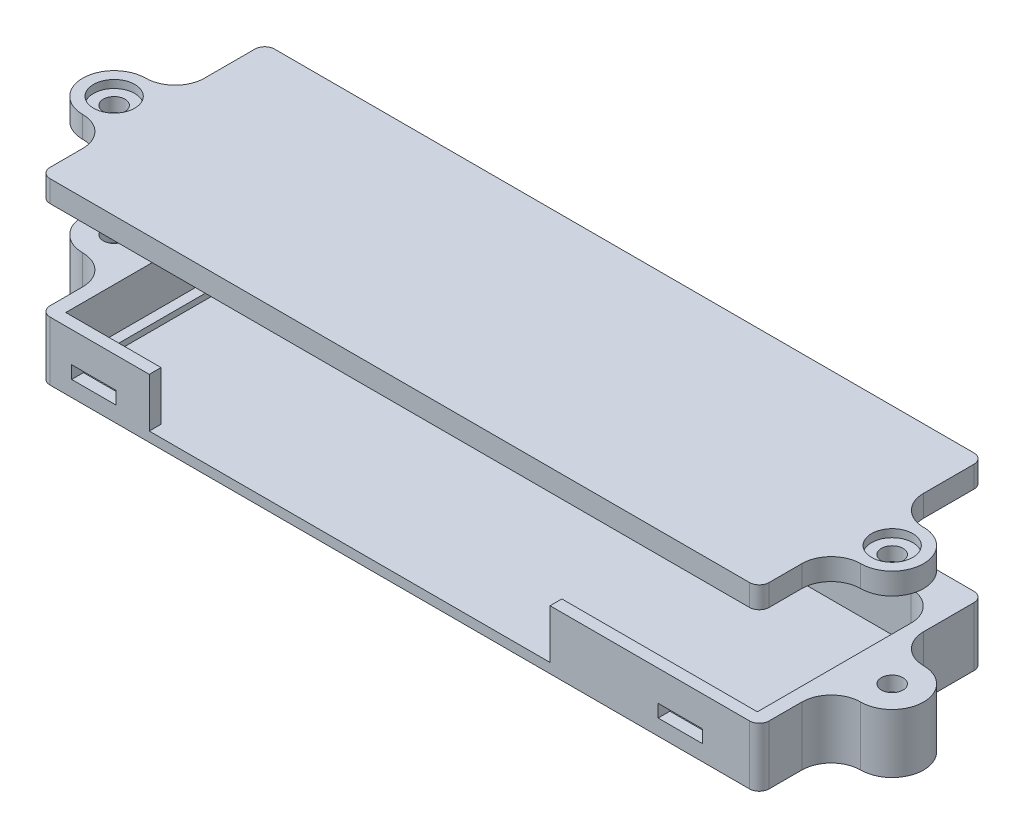
from build123d import *

# Parameters (mm, degrees)
SKETCH_1_W          = 73.2
SKETCH_1_H          = 22.85
EXTRUDE_1_DEPTH     = 5
SKETCH_2_W          = 73.2
SKETCH_2_H          = 22.85
EXTRUDE_2_DEPTH     = 1
SKETCH_3_W          = 1
SKETCH_3_H          = 14.570353531
EXTRUDE_3_DEPTH     = 0.6
CUT_EXTRUDE_1_REACH = 24.85
SKETCH_4_W          = 10.95
SKETCH_4_H          = 5
CUT_EXTRUDE_2_REACH = 24.85
SKETCH_5_W          = 40.8
SKETCH_5_H          = 5
SKETCH_5_W_2        = 4.5
SKETCH_5_H_2        = 1.3
FILLET_1_R          = 1
SKETCH_6_R          = 1.1
EXTRUDE_4_DEPTH     = 6
CUT_EXTRUDE_3_DEPTH = 4.5
SKETCH_8_R          = 1.1
EXTRUDE_5_DEPTH     = 2.2
SKETCH_9_R          = 2.1
CUT_EXTRUDE_4_DEPTH = 0.8


with BuildPart() as part:
    # 草图1 → 凸台-拉伸1 (new body)
    with BuildSketch(Plane(origin=(0, 0, 0), x_dir=(1, 0, 0), z_dir=(0, 1, 0))):
        with Locations((0, 0.9)):
            Rectangle(SKETCH_1_W, SKETCH_1_H)
        with BuildLine():
            Line((-35.2, -9.325), (35.2, -9.325))
            Line((35.2, -9.325), (35.2, 6.325))
            ThreePointArc((35.2, 6.325), (34.321320344, 8.446320344), (32.2, 9.325))
            Line((32.2, 9.325), (-35.2, 9.325))
            Line((-35.2, 9.325), (-35.2, -9.325))
        make_face(mode=Mode.SUBTRACT)
    extrude(amount=EXTRUDE_1_DEPTH)

    # 草图2 → 凸台-拉伸2 (add)
    with BuildSketch(Plane.XZ):
        with Locations((0, -0.9)):
            Rectangle(SKETCH_2_W, SKETCH_2_H)
    extrude(amount=EXTRUDE_2_DEPTH)

    # 草图3 → 凸台-拉伸3 (add)
    with BuildSketch(Plane(origin=(0, 0, 0), x_dir=(1, 0, 0), z_dir=(0, 1, 0))):
        with Locations((-34.7, -0.005928717)):
            Rectangle(SKETCH_3_W, SKETCH_3_H)
        with Locations((34.7, -0.005928717)):
            Rectangle(SKETCH_3_W, SKETCH_3_H)
    extrude(amount=EXTRUDE_3_DEPTH)

    # 草图4 → 切除-拉伸1 (cut, up to next)
    with BuildSketch(Plane(origin=(0, 0, -12.325), x_dir=(-1, 0, 0), z_dir=(0, 0, -1)), mode=Mode.PRIVATE) as cut_extrude_1_sk1:
        with Locations((23.425, 2.5)):
            Rectangle(SKETCH_4_W, SKETCH_4_H)
    cut_extrude_1_tool1 = extrude(cut_extrude_1_sk1.sketch, amount=-CUT_EXTRUDE_1_REACH, mode=Mode.PRIVATE) & part.part
    add(cut_extrude_1_tool1.solids().sort_by_distance((-23.425, 2.5, -12.325))[0], mode=Mode.SUBTRACT)

    # 草图5 → 切除-拉伸2 (cut, up to next)
    with BuildSketch(Plane.XY.offset(10.525), mode=Mode.PRIVATE) as cut_extrude_2_sk1:
        with Locations((-5.1, 2.5)):
            Rectangle(SKETCH_5_W, SKETCH_5_H)
    cut_extrude_2_tool1 = extrude(cut_extrude_2_sk1.sketch, amount=-CUT_EXTRUDE_2_REACH, mode=Mode.PRIVATE) & part.part
    add(cut_extrude_2_tool1.solids().sort_by_distance((-5.1, 2.5, 10.525))[0], mode=Mode.SUBTRACT)
    # 草图5 → 切除-拉伸2 (cut, up to next)
    with BuildSketch(Plane.XY.offset(10.525), mode=Mode.PRIVATE) as cut_extrude_2_sk2:
        with Locations((-31.15, 1.25)):
            Rectangle(SKETCH_5_W_2, SKETCH_5_H_2)
    cut_extrude_2_tool2 = extrude(cut_extrude_2_sk2.sketch, amount=-CUT_EXTRUDE_2_REACH, mode=Mode.PRIVATE) & part.part
    add(cut_extrude_2_tool2.solids().sort_by_distance((-31.15, 1.25, 10.525))[0], mode=Mode.SUBTRACT)
    # 草图5 → 切除-拉伸2 (cut, up to next)
    with BuildSketch(Plane.XY.offset(10.525), mode=Mode.PRIVATE) as cut_extrude_2_sk3:
        with Locations((28.55, 1.25)):
            Rectangle(SKETCH_5_W_2, SKETCH_5_H_2)
    cut_extrude_2_tool3 = extrude(cut_extrude_2_sk3.sketch, amount=-CUT_EXTRUDE_2_REACH, mode=Mode.PRIVATE) & part.part
    add(cut_extrude_2_tool3.solids().sort_by_distance((28.55, 1.25, 10.525))[0], mode=Mode.SUBTRACT)

    # 圆角1
    fillet_1_edges = [part.edges().sort_by_distance(p)[0] for p in [
        (-36.6, 2, -12.325),
        (36.6, 2, -12.325),
        (36.6, 2, 10.525),
        (-36.6, 2, 10.525),
    ]]
    fillet(fillet_1_edges, radius=FILLET_1_R)

    # 草图6 → 凸台-拉伸4 (add)
    with BuildSketch(Plane(origin=(0, 5, 0), x_dir=(1, 0, 0), z_dir=(0, 1, 0))):
        with BuildLine():
            Line((-36.6, 6.2), (-36.6, -6.2))
            ThreePointArc((-36.6, -6.2), (-37.478679656, -4.078679656), (-39.6, -3.2))
            ThreePointArc((-39.6, -3.2), (-42.8, 0), (-39.6, 3.2))
            ThreePointArc((-39.6, 3.2), (-37.478679656, 4.078679656), (-36.6, 6.2))
        make_face()
        with Locations((-39.6, 0)):
            Circle(SKETCH_6_R, mode=Mode.SUBTRACT)
        with BuildLine():
            Line((36.6, 6.2), (36.6, -6.2))
            ThreePointArc((36.6, -6.2), (37.478679656, -4.078679656), (39.6, -3.2))
            ThreePointArc((39.6, -3.2), (42.8, 0), (39.6, 3.2))
            ThreePointArc((39.6, 3.2), (37.478679656, 4.078679656), (36.6, 6.2))
        make_face()
        with Locations((39.6, 0)):
            Circle(SKETCH_6_R, mode=Mode.SUBTRACT)
    extrude(amount=-EXTRUDE_4_DEPTH)

    # 草图7 → 切除-拉伸3 (cut)
    with BuildSketch(Plane.XZ.offset(1)):
        Polygon((-37.55, 1.183568052), (-39.6, 2.367136104), (-41.65, 1.183568052), (-41.65, -1.183568052), (-39.6, -2.367136104), (-37.55, -1.183568052), align=None)
        Polygon((39.6, 2.367136104), (37.55, 1.183568052), (37.55, -1.183568052), (39.6, -2.367136104), (41.65, -1.183568052), (41.65, 1.183568052), align=None)
    extrude(amount=-CUT_EXTRUDE_3_DEPTH, mode=Mode.SUBTRACT)


with BuildPart() as body_2:
    # 草图8 → 凸台-拉伸5 (new body)
    with BuildSketch(Plane(origin=(0, 15, 0), x_dir=(1, 0, 0), z_dir=(0, 1, 0))):
        with BuildLine():
            Line((36.6, -9.525), (36.6, -6.2))
            ThreePointArc((36.6, -6.2), (37.478679656, -4.078679656), (39.6, -3.2))
            ThreePointArc((39.6, -3.2), (42.8, 0), (39.6, 3.2))
            ThreePointArc((39.6, 3.2), (37.478679656, 4.078679656), (36.6, 6.2))
            Line((36.6, 6.2), (36.6, 11.325))
            ThreePointArc((36.6, 11.325), (36.307106781, 12.032106781), (35.6, 12.325))
            Line((35.6, 12.325), (-35.6, 12.325))
            ThreePointArc((-35.6, 12.325), (-36.307106781, 12.032106781), (-36.6, 11.325))
            Line((-36.6, 11.325), (-36.6, 6.2))
            ThreePointArc((-36.6, 6.2), (-37.478679656, 4.078679656), (-39.6, 3.2))
            ThreePointArc((-39.6, 3.2), (-42.8, 0), (-39.6, -3.2))
            ThreePointArc((-39.6, -3.2), (-37.478679656, -4.078679656), (-36.6, -6.2))
            Line((-36.6, -6.2), (-36.6, -9.525))
            ThreePointArc((-36.6, -9.525), (-36.307106781, -10.232106781), (-35.6, -10.525))
            Line((-35.6, -10.525), (35.6, -10.525))
            ThreePointArc((35.6, -10.525), (36.307106781, -10.232106781), (36.6, -9.525))
        make_face()
        with Locations((39.6, 0)):
            Circle(SKETCH_8_R, mode=Mode.SUBTRACT)
        with Locations((-39.6, 0)):
            Circle(SKETCH_8_R, mode=Mode.SUBTRACT)
    extrude(amount=EXTRUDE_5_DEPTH)

    # 草图9 → 切除-拉伸4 (cut)
    with BuildSketch(Plane(origin=(0, 17.2, 0), x_dir=(1, 0, 0), z_dir=(0, 1, 0))):
        with Locations((-39.6, 0)):
            Circle(SKETCH_9_R)
        with Locations((39.6, 0)):
            Circle(SKETCH_9_R)
    extrude(amount=-CUT_EXTRUDE_4_DEPTH, mode=Mode.SUBTRACT)


solid = Compound([part.part, body_2.part])
